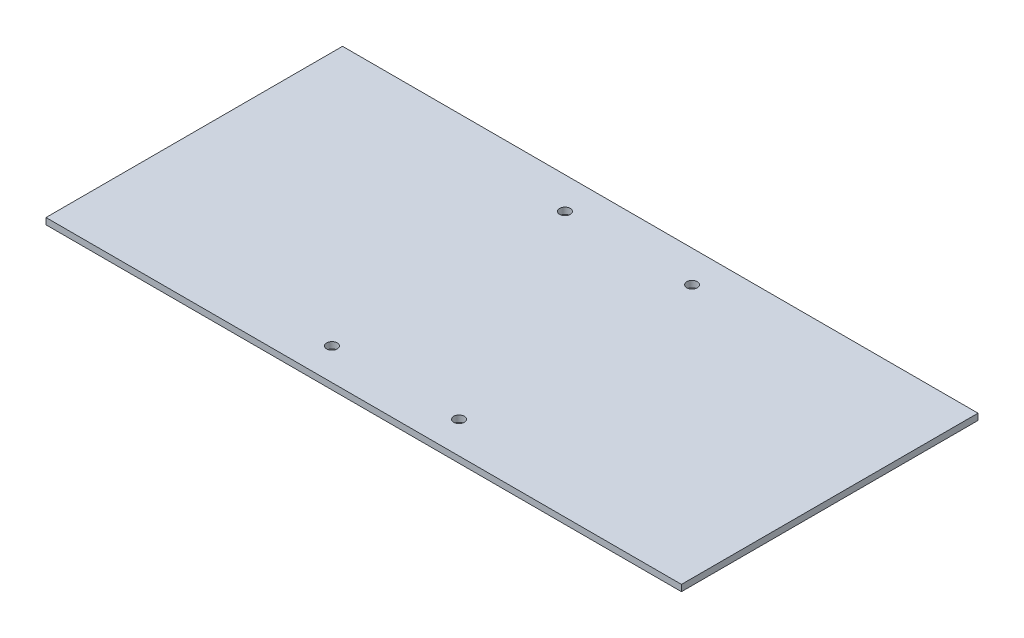
from build123d import *

# Parameters (mm, degrees)
SKETCH_1_W          = 300
SKETCH_1_H          = 140
EXTRUDE_1_DEPTH     = 3
SKETCH_2_R          = 2.5
CUT_EXTRUDE_1_DEPTH = 3


with BuildPart() as part:
    # 草图1 → 凸台-拉伸1 (new body)
    with BuildSketch(Plane(origin=(0, 0, 0), x_dir=(1, 0, 0), z_dir=(0, 1, 0))):
        Rectangle(SKETCH_1_W, SKETCH_1_H)
    extrude(amount=EXTRUDE_1_DEPTH)

    # 草图2 → 切除-拉伸1 (cut)
    with BuildSketch(Plane(origin=(0, 3, 0), x_dir=(1, 0, 0), z_dir=(0, 1, 0))):
        with Locations((-30, 55)):
            Circle(SKETCH_2_R)
        with Locations((30, 55)):
            Circle(SKETCH_2_R)
    cut_extrude_1 = extrude(amount=-CUT_EXTRUDE_1_DEPTH, mode=Mode.SUBTRACT)

    # 镜向1: 切除-拉伸1 across plane
    add(cut_extrude_1.mirror(Plane.XY), mode=Mode.SUBTRACT)


solid = part.part
